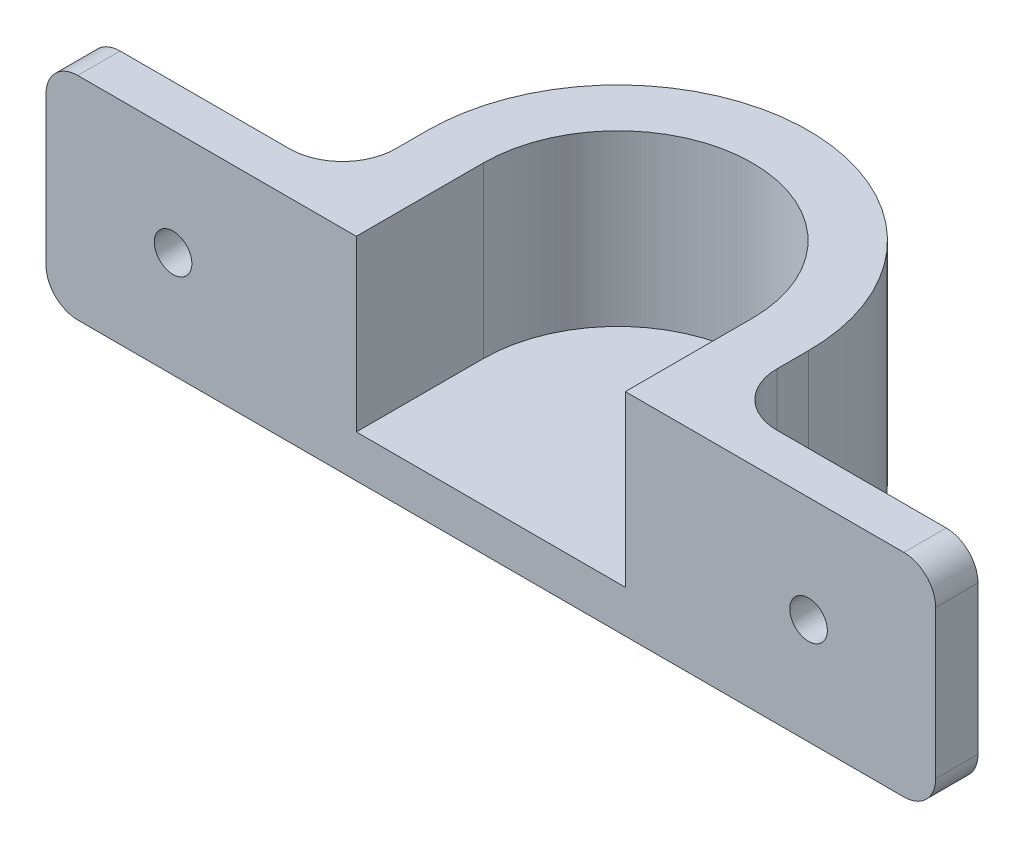
from build123d import *

# Parameters (mm, degrees)
BOSS_EXTRUDE1_DEPTH = 20
SKETCH2_R           = 1.775
CUT_EXTRUDE1_DEPTH  = 5
FILLET1_R           = 3
FILLET2_R           = 5
BOSS_EXTRUDE2_DEPTH = 4


with BuildPart() as part:
    # Sketch1 → Boss-Extrude1 (new body)
    with BuildSketch(Plane(origin=(0, 0, 0), x_dir=(1, 0, 0), z_dir=(0, 1, 0))):
        with BuildLine():
            Line((0, 0), (0, 4))
            Line((0, 4), (24, 4))
            Line((24, 4), (24, 12))
            ThreePointArc((24, 12), (42, 30), (60, 12))
            Line((60, 12), (60, 4))
            Line((60, 4), (84, 4))
            Line((84, 4), (84, 0))
            Line((84, 0), (54.7, 0))
            Line((54.7, 0), (54.7, 12))
            ThreePointArc((54.7, 12), (42, 24.7), (29.3, 12))
            Line((29.3, 12), (29.3, 0))
            Line((29.3, 0), (0, 0))
        make_face()
    extrude(amount=BOSS_EXTRUDE1_DEPTH)

    # Sketch2 → Cut-Extrude1 (cut, through all)
    with BuildSketch(Plane(origin=(0, 0, -4), x_dir=(-1, 0, 0), z_dir=(0, 0, -1))):
        with Locations((-72, 10)):
            Circle(SKETCH2_R)
        with Locations((-12, 10)):
            Circle(SKETCH2_R)
    extrude(amount=-CUT_EXTRUDE1_DEPTH, mode=Mode.SUBTRACT)

    # Fillet1
    fillet1_edges = [part.edges().sort_by_distance(p)[0] for p in [
        (0, 0, -2),
        (84, 0, -2),
        (84, 20, -2),
        (0, 20, -2),
    ]]
    fillet(fillet1_edges, radius=FILLET1_R)

    # Fillet2
    fillet2_edges = [part.edges().sort_by_distance(p)[0] for p in [
        (24, 10, -4),
        (60, 10, -4),
    ]]
    fillet(fillet2_edges, radius=FILLET2_R)

    # Sketch4 → Boss-Extrude2 (add)
    with BuildSketch(Plane.XZ):
        with BuildLine():
            Line((29.3, 0), (54.7, 0))
            Line((54.7, 0), (54.7, -12))
            ThreePointArc((54.7, -12), (42, -24.7), (29.3, -12))
            Line((29.3, -12), (29.3, 0))
        make_face()
    extrude(amount=-BOSS_EXTRUDE2_DEPTH)


solid = part.part
